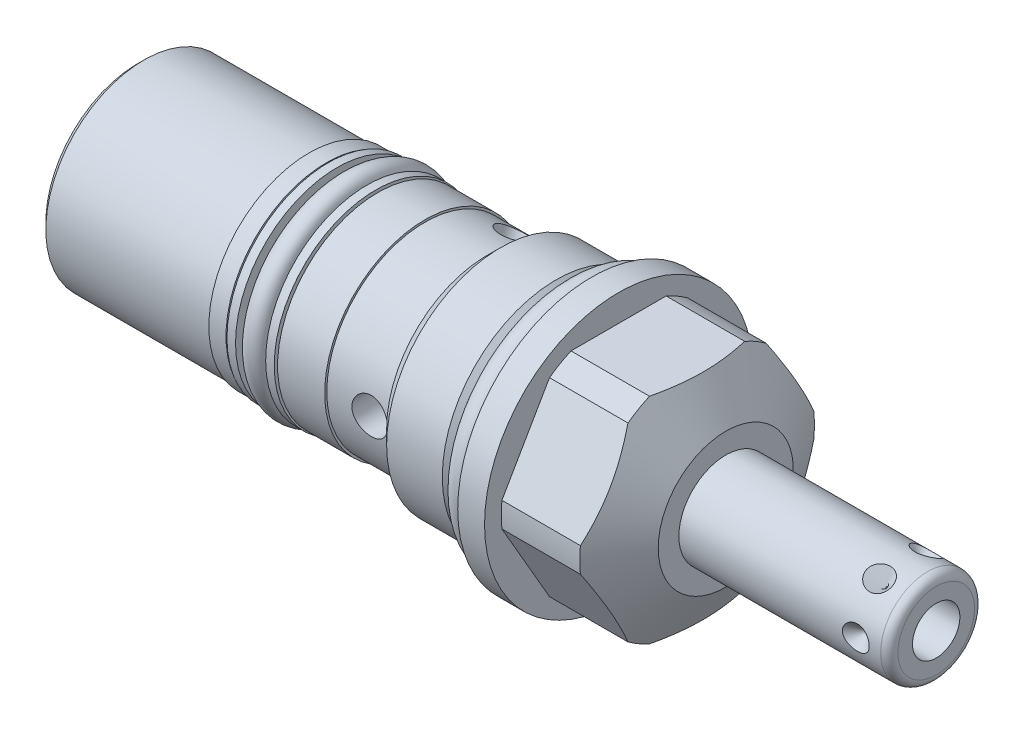
from build123d import *

# Parameters (mm, degrees)
SKETCH2_OUTSIDE_W  = 50.328
SKETCH2_OUTSIDE_H  = 50.328
CUT_EXTRUDE1_DEPTH = 12.7
CIRPATTERN1_COUNT  = 6
SKETCH6_W          = 13.716
SKETCH6_H          = 0.254
SKETCH7_R          = 0.8001
CUT_EXTRUDE2_DEPTH = 0.762
SKETCH8_W          = 6.1087
SKETCH8_H          = 2.0447
SKETCH9_W          = 1.016
SKETCH9_H          = 2.1844
SKETCH10_W         = 2.1082
SKETCH10_H         = 10.82675
CIRPATTERN2_COUNT  = 3
CHAMFER1_SIZE      = 0.762
SKETCH11_R         = 1.4732
SKETCH12_R         = 1.3081


with BuildPart() as part:
    # Sketch1 → Revolve1 (revolve)
    with BuildSketch(Plane.XY, mode=Mode.PRIVATE) as revolve1_sk:
        Polygon((0, 15.875), (3.175, 15.875), (3.175, 13.8938), (12.472790334, 13.8938), (15.875, 8.001), (15.875, 0), (-53.7972, 0), (-53.7972, 11.6205), (-12.4206, 11.6205), (-12.4206, 11.8745), (-10.80135, 13.49375), (-4.21005, 13.49375), (-2.7178, 12.0015), (0, 12.0015), align=None)
    revolve(revolve1_sk.sketch.rotate(Axis((0, 0, 0), (1, 0, 0)), 90), axis=Axis((0, 0, 0), (1, 0, 0)))  # turned: the seam where the file's is

    # Sketch2 outside → Cut-Extrude1 (cut)
    with BuildSketch(Plane(origin=(15.875, 0, 0), x_dir=(0, 0, -1), z_dir=(1, 0, 0))):
        Rectangle(SKETCH2_OUTSIDE_W, SKETCH2_OUTSIDE_H)
        Polygon((7.332348419, 12.7), (-7.332348419, 12.7), (-14.664696837, 0), (-7.332348419, -12.7), (7.332348419, -12.7), (14.664696837, 0), align=None, mode=Mode.SUBTRACT)
    extrude(amount=-CUT_EXTRUDE1_DEPTH, mode=Mode.SUBTRACT)

    # Sketch3 → Revolve2 (revolve)
    with BuildSketch(Plane.XY, mode=Mode.PRIVATE) as revolve2_sk:
        with BuildLine():
            Line((15.875, 5.55625), (39.7764, 5.55625))
            ThreePointArc((39.7764, 5.55625), (40.49482049, 5.25867049), (40.7924, 4.54025))
            Line((40.7924, 4.54025), (40.7924, 0))
            Line((40.7924, 0), (15.875, 0))
            Line((15.875, 0), (15.875, 5.55625))
        make_face()
    revolve(revolve2_sk.sketch.rotate(Axis((0, 0, 0), (1, 0, 0)), 90), axis=Axis((0, 0, 0), (1, 0, 0)))  # turned: the seam where the file's is

    # Sketch4 → Cut-Revolve1 (revolve, cut)
    with BuildSketch(Plane(origin=(0, 0, 0), x_dir=(1, 0, 0), z_dir=(0, 1, 0)), mode=Mode.PRIVATE) as cut_revolve1_sk:
        Polygon((38.4175, 5.55625), (36.83, 5.55625), (36.83, 3.96875), align=None)
    cut_revolve1 = revolve(cut_revolve1_sk.sketch.rotate(Axis((36.83, 0, -10.073804773), (0, 0, 1)), 180), axis=Axis((36.83, 0, -10.073804773), (0, 0, 1)), mode=Mode.SUBTRACT)  # turned: the seam where the file's is

    # CirPattern1: Cut-Revolve1 ×6 about axis
    cirpattern1_axis = Axis((0, 0, 0), (-1, 0, 0))
    for i in range(1, CIRPATTERN1_COUNT):
        add(cut_revolve1.rotate(cirpattern1_axis, i * 360 / CIRPATTERN1_COUNT), mode=Mode.SUBTRACT)

    # Sketch5 → Cut-Revolve2 (revolve, cut)
    with BuildSketch(Plane.XY, mode=Mode.PRIVATE) as cut_revolve2_sk:
        Polygon((40.7924, 2.8067), (30.6324, 2.8067), (28.945964501, 0), (40.7924, 0), align=None)
    revolve(cut_revolve2_sk.sketch.rotate(Axis((0, 0, 0), (1, 0, 0)), 90), axis=Axis((0, 0, 0), (1, 0, 0)), mode=Mode.SUBTRACT)  # turned: the seam where the file's is

    # Sketch6 → Revolve3 (revolve)
    with BuildSketch(Plane.XY, mode=Mode.PRIVATE) as revolve3_sk:
        with Locations((-26.6192, 11.7475)):
            Rectangle(SKETCH6_W, SKETCH6_H)
    revolve(revolve3_sk.sketch.rotate(Axis((0, 0, 0), (-1, 0, 0)), 270), axis=Axis((0, 0, 0), (-1, 0, 0)))  # turned: the seam where the file's is

    # Sketch7 → Cut-Extrude2 (cut)
    with BuildSketch(Plane.ZY.offset(53.7972)):
        Circle(SKETCH7_R)
    extrude(amount=-CUT_EXTRUDE2_DEPTH, mode=Mode.SUBTRACT)

    # Sketch8 → Cut-Revolve3 (revolve, cut)
    with BuildSketch(Plane.XY, mode=Mode.PRIVATE) as cut_revolve3_sk:
        with Locations((-28.39085, 10.85215)):
            Rectangle(SKETCH8_W, SKETCH8_H)
    revolve(cut_revolve3_sk.sketch.rotate(Axis((0, 0, 0), (-1, 0, 0)), 270), axis=Axis((0, 0, 0), (-1, 0, 0)), mode=Mode.SUBTRACT)  # turned: the seam where the file's is

    # Sketch9 → Revolve4 (revolve)
    with BuildSketch(Plane.XY, mode=Mode.PRIVATE) as revolve4_sk:
        with Locations((-26.0985, 10.922)):
            Rectangle(SKETCH9_W, SKETCH9_H)
        with Locations((-30.6832, 10.922)):
            Rectangle(SKETCH9_W, SKETCH9_H)
    revolve(revolve4_sk.sketch.rotate(Axis((0, 0, 0), (-1, 0, 0)), 270), axis=Axis((0, 0, 0), (-1, 0, 0)))  # turned: the seam where the file's is

    # Sketch10 → Cut-Revolve4 (revolve, cut)
    with BuildSketch(Plane(origin=(0, 0, 0), x_dir=(1, 0, 0), z_dir=(0, 1, 0))):
        with Locations((-15.7353, -6.207125)):
            Rectangle(SKETCH10_W, SKETCH10_H)
    cut_revolve4 = revolve(axis=Axis((-14.6812, 0, -23.036850257), (0, 0, 1)), mode=Mode.SUBTRACT)

    # CirPattern2: Cut-Revolve4 ×3 about axis
    cirpattern2_axis = Axis((0, 0, 0), (1, 0, 0))
    for i in range(1, CIRPATTERN2_COUNT):
        add(cut_revolve4.rotate(cirpattern2_axis, i * 360 / CIRPATTERN2_COUNT), mode=Mode.SUBTRACT)

    # Chamfer1
    chamfer1_edges = [part.edges().sort_by_distance(p)[0] for p in [
        (-53.7972, 0, -11.6205),
    ]]
    chamfer(chamfer1_edges, length=CHAMFER1_SIZE)


with BuildPart() as body_2:
    # Sketch11 → Revolve5 (revolve)
    with BuildSketch(Plane.XY, mode=Mode.PRIVATE) as revolve5_sk:
        with Locations((-1.4732, 13.4747)):
            Circle(SKETCH11_R)
    revolve(revolve5_sk.sketch.rotate(Axis((0, 0, 0), (1, 0, 0)), 90), axis=Axis((0, 0, 0), (1, 0, 0)))  # turned: the seam where the file's is


with BuildPart() as body_3:
    # Sketch12 → Revolve7 (revolve)
    with BuildSketch(Plane.XY, mode=Mode.PRIVATE) as revolve7_sk:
        with Locations((-28.39085, 11.1379)):
            Circle(SKETCH12_R)
    revolve(revolve7_sk.sketch.rotate(Axis((0, 0, 0), (-1, 0, 0)), 270), axis=Axis((0, 0, 0), (-1, 0, 0)))  # turned: the seam where the file's is


solid = Compound([part.part, body_2.part, body_3.part])
